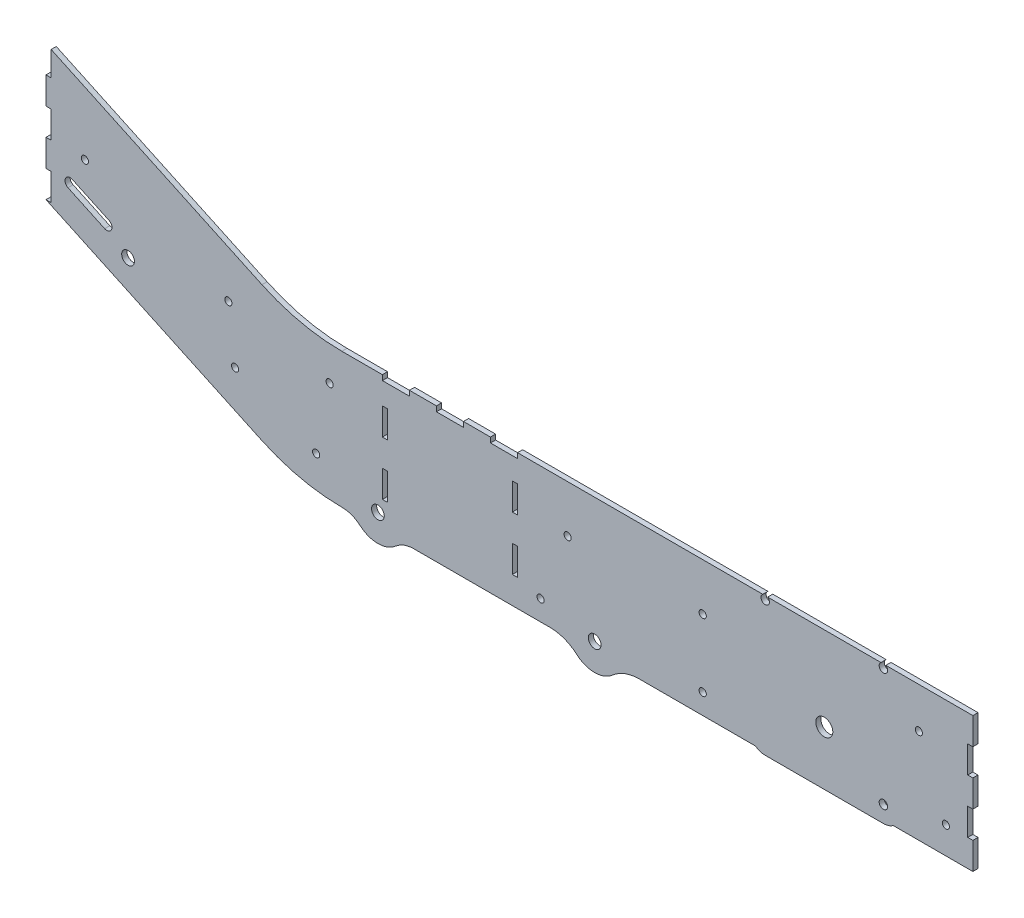
from build123d import *

# Parameters (mm, degrees)
SKETCH1_R           = 3.3782
SKETCH1_R_2         = 6
SKETCH1_R_3         = 8
BOSS_EXTRUDE1_DEPTH = 4.826
SKETCH2_W           = 4.826
SKETCH2_H           = 25.4
BOSS_EXTRUDE2_DEPTH = 4.826
SKETCH3_W           = 4.826
SKETCH3_H           = 25.4
CUT_EXTRUDE1_DEPTH  = 4.826
SKETCH4_W           = 4.826
SKETCH4_H           = 25.4
BOSS_EXTRUDE3_DEPTH = 4.826
SKETCH5_W           = 4.826
SKETCH5_H           = 25.4
CUT_EXTRUDE2_DEPTH  = 4.826
SKETCH6_W           = 4.826
SKETCH6_H           = 25.4
CUT_EXTRUDE3_DEPTH  = 9.652
SKETCH7_W           = 25.4
SKETCH7_H           = 4.826
CUT_EXTRUDE4_DEPTH  = 5.826
SKETCH9_W           = 4.826
SKETCH9_H           = 25.4
CUT_EXTRUDE5_DEPTH  = 5.826
BOSS_EXTRUDE4_DEPTH = 4.826
SKETCH11_R          = 4
CUT_EXTRUDE6_DEPTH  = 5.826


with BuildPart() as part:
    # Sketch1 → Boss-Extrude1 (new body)
    with BuildSketch(Plane.XY):
        with BuildLine():
            ThreePointArc((192.003501193, 390.374510077), (153.520537835, 394.589080012), (116.861974256, 407.032985542))
            Line((116.861974256, 407.032985542), (-86.189766395, 501.71756721))
            Line((-86.189766395, 501.71756721), (-86.189766395, 476.31756721))
            Line((-86.189766395, 476.31756721), (-81.363766395, 476.31756721))
            Line((-81.363766395, 476.31756721), (-81.363766395, 450.91756721))
            Line((-81.363766395, 450.91756721), (-86.189766395, 450.91756721))
            Line((-86.189766395, 450.91756721), (-86.189766395, 425.51756721))
            Line((-86.189766395, 425.51756721), (-81.363766395, 425.51756721))
            Line((-81.363766395, 425.51756721), (-81.363766395, 400.11756721))
            Line((-81.363766395, 400.11756721), (-86.189766395, 400.11756721))
            Line((-86.189766395, 400.11756721), (-86.189766395, 374.71756721))
            Line((-86.189766395, 374.71756721), (116.861974256, 280.032985542))
            ThreePointArc((116.861974256, 280.032985542), (153.520537835, 267.589080012), (192.003501193, 263.374510077))
            ThreePointArc((192.003501193, 263.374510077), (201.203503254, 261.71550325), (209.244538804, 256.947475478))
            ThreePointArc((209.244538804, 256.947475478), (225.871079853, 250.749510077), (242.497620902, 256.947475478))
            ThreePointArc((242.497620902, 256.947475478), (250.538656453, 261.71550325), (259.738658513, 263.374510077))
            Line((259.738658513, 263.374510077), (387.768126915, 263.374510077))
            ThreePointArc((387.768126915, 263.374510077), (401.20665362, 260.925821414), (412.917790929, 253.894510077))
            ThreePointArc((412.917790929, 253.894510077), (429.684233605, 247.574510077), (446.45067628, 253.894510077))
            ThreePointArc((446.45067628, 253.894510077), (458.161813589, 260.925821414), (471.600340294, 263.374510077))
            Line((471.600340294, 263.374510077), (624.413499087, 263.374510077))
            ThreePointArc((624.413499087, 263.374510077), (627.977205024, 263.123267502), (631.470410593, 262.374510077))
            ThreePointArc((631.470410593, 262.374510077), (645.584233605, 260.374510077), (659.698056616, 262.374510077))
            ThreePointArc((659.698056616, 262.374510077), (663.191262186, 263.123267502), (666.754968122, 263.374510077))
            Line((666.754968122, 263.374510077), (790.110233605, 263.374510077))
            Line((790.110233605, 263.374510077), (790.110233605, 288.774510077))
            Line((790.110233605, 288.774510077), (785.284233605, 288.774510077))
            Line((785.284233605, 288.774510077), (785.284233605, 314.174510077))
            Line((785.284233605, 314.174510077), (790.110233605, 314.174510077))
            Line((790.110233605, 314.174510077), (790.110233605, 339.574510077))
            Line((790.110233605, 339.574510077), (785.284233605, 339.574510077))
            Line((785.284233605, 339.574510077), (785.284233605, 364.974510077))
            Line((785.284233605, 364.974510077), (790.110233605, 364.974510077))
            Line((790.110233605, 364.974510077), (790.110233605, 390.374510077))
            Line((790.110233605, 390.374510077), (192.003501193, 390.374510077))
        make_face()
        with BuildLine():
            ThreePointArc((-26.914752452, 387.434325035), (-24.580466803, 381.020927923), (-30.993863915, 378.686642274))
            Line((-30.993863915, 378.686642274), (-65.524190601, 394.788398047))
            ThreePointArc((-65.524190601, 394.788398047), (-67.85847625, 401.201795158), (-61.445079138, 403.536080807))
            Line((-61.445079138, 403.536080807), (-26.914752452, 387.434325035))
        make_face(mode=Mode.SUBTRACT)
        with Locations((85.260233605, 377.674510077)):
            Circle(SKETCH1_R, mode=Mode.SUBTRACT)
        with Locations((-49.613766395, 425.51756721)):
            Circle(SKETCH1_R, mode=Mode.SUBTRACT)
        with Locations((225.871079853, 276.149510077)):
            Circle(SKETCH1_R_2, mode=Mode.SUBTRACT)
        with Locations((167.810233605, 295.124510077)):
            Circle(SKETCH1_R, mode=Mode.SUBTRACT)
        with Locations((91.610233605, 326.874510077)):
            Circle(SKETCH1_R, mode=Mode.SUBTRACT)
        with Locations((-9.032874317, 365.922075979)):
            Circle(SKETCH1_R_2, mode=Mode.SUBTRACT)
        with Locations((180.510233605, 358.624510077)):
            Circle(SKETCH1_R, mode=Mode.SUBTRACT)
        with Locations((429.684233605, 272.974510077)):
            Circle(SKETCH1_R_2, mode=Mode.SUBTRACT)
        with Locations((378.858833605, 282.424510077)):
            Circle(SKETCH1_R, mode=Mode.SUBTRACT)
        with Locations((531.258833605, 282.424510077)):
            Circle(SKETCH1_R, mode=Mode.SUBTRACT)
        with Locations((759.884233605, 288.774510077)):
            Circle(SKETCH1_R, mode=Mode.SUBTRACT)
        with Locations((404.258833605, 345.924510077)):
            Circle(SKETCH1_R, mode=Mode.SUBTRACT)
        with Locations((531.258833605, 345.924510077)):
            Circle(SKETCH1_R, mode=Mode.SUBTRACT)
        with Locations((645.584233605, 311.174510077)):
            Circle(SKETCH1_R_3, mode=Mode.SUBTRACT)
        with Locations((734.484233605, 352.274510077)):
            Circle(SKETCH1_R, mode=Mode.SUBTRACT)
    extrude(amount=BOSS_EXTRUDE1_DEPTH)

    # Sketch2 → Boss-Extrude2 (add)
    with BuildSketch(Plane(origin=(785.284233605, 0, 0), x_dir=(0, 0, -1), z_dir=(1, 0, 0))):
        with Locations((-2.413, 352.274510077)):
            Rectangle(SKETCH2_W, SKETCH2_H)
        with Locations((-2.413, 301.474510077)):
            Rectangle(SKETCH2_W, SKETCH2_H)
    extrude(amount=BOSS_EXTRUDE2_DEPTH)

    # Sketch3 → Cut-Extrude1 (cut)
    with BuildSketch(Plane(origin=(790.110233605, 0, 0), x_dir=(0, 0, -1), z_dir=(1, 0, 0))):
        with Locations((-2.413, 377.674510077)):
            Rectangle(SKETCH3_W, SKETCH3_H)
        with Locations((-2.413, 326.874510077)):
            Rectangle(SKETCH3_W, SKETCH3_H)
        with Locations((-2.413, 276.074510077)):
            Rectangle(SKETCH3_W, SKETCH3_H)
    extrude(amount=-CUT_EXTRUDE1_DEPTH, mode=Mode.SUBTRACT)

    # Sketch4 → Boss-Extrude3 (add)
    with BuildSketch(Plane.ZY.offset(81.363766395)):
        with Locations((2.413, 463.61756721)):
            Rectangle(SKETCH4_W, SKETCH4_H)
        with Locations((2.413, 412.81756721)):
            Rectangle(SKETCH4_W, SKETCH4_H)
    extrude(amount=BOSS_EXTRUDE3_DEPTH)

    # Sketch5 → Cut-Extrude2 (cut)
    with BuildSketch(Plane.ZY.offset(86.189766395)):
        with Locations((2.413, 387.41756721)):
            Rectangle(SKETCH5_W, SKETCH5_H)
        with Locations((2.413, 438.21756721)):
            Rectangle(SKETCH5_W, SKETCH5_H)
        with Locations((2.413, 489.01756721)):
            Rectangle(SKETCH5_W, SKETCH5_H)
    extrude(amount=-CUT_EXTRUDE2_DEPTH, mode=Mode.SUBTRACT)

    # Sketch6 → Cut-Extrude3 (cut)
    with BuildSketch(Plane(origin=(790.110233605, 0, 0), x_dir=(0, 0, -1), z_dir=(1, 0, 0))):
        with Locations((-2.413, 352.274510077)):
            Rectangle(SKETCH6_W, SKETCH6_H)
        with Locations((-2.413, 301.474510077)):
            Rectangle(SKETCH6_W, SKETCH6_H)
    extrude(amount=-CUT_EXTRUDE3_DEPTH, mode=Mode.SUBTRACT)

    # Sketch7 → Cut-Extrude4 (cut, through all)
    with BuildSketch(Plane.XY.offset(4.826)):
        with Locations((293.603501193, 387.961510077)):
            Rectangle(SKETCH7_W, SKETCH7_H)
        with Locations((344.403501193, 387.961510077)):
            Rectangle(SKETCH7_W, SKETCH7_H)
        with Locations((242.803501193, 387.961510077)):
            Rectangle(SKETCH7_W, SKETCH7_H)
    extrude(amount=-CUT_EXTRUDE4_DEPTH, mode=Mode.SUBTRACT)

    # Sketch9 → Cut-Extrude5 (cut, through all)
    with BuildSketch(Plane(origin=(0, 0, 0), x_dir=(-1, 0, 0), z_dir=(0, 0, -1))):
        with Locations((-354.690501193, 352.274510077)):
            Rectangle(SKETCH9_W, SKETCH9_H)
        with Locations((-354.690501193, 301.474510077)):
            Rectangle(SKETCH9_W, SKETCH9_H)
        with Locations((-232.516501193, 301.474510077)):
            Rectangle(SKETCH9_W, SKETCH9_H)
        with Locations((-232.516501193, 352.274510077)):
            Rectangle(SKETCH9_W, SKETCH9_H)
    extrude(amount=-CUT_EXTRUDE5_DEPTH, mode=Mode.SUBTRACT)

    # Sketch10 → Boss-Extrude4 (add)
    with BuildSketch(Plane.XY.offset(4.826)):
        with BuildLine():
            ThreePointArc((580.854886872, 263.374510077), (585.212430925, 261.14348344), (590.047133605, 260.374510077))
            Line((590.047133605, 260.374510077), (645.584233605, 260.374510077))
            ThreePointArc((645.584233605, 260.374510077), (638.456821732, 260.876995228), (631.470410593, 262.374510077))
            ThreePointArc((631.470410593, 262.374510077), (627.977205024, 263.123267502), (624.413499087, 263.374510077))
            Line((624.413499087, 263.374510077), (580.854886872, 263.374510077))
        make_face()
        with BuildLine():
            ThreePointArc((659.698056616, 262.374510077), (652.711645477, 260.876995228), (645.584233605, 260.374510077))
            Line((645.584233605, 260.374510077), (701.172133605, 260.374510077))
            ThreePointArc((701.172133605, 260.374510077), (706.006836284, 261.14348344), (710.364380338, 263.374510077))
            Line((710.364380338, 263.374510077), (666.754968122, 263.374510077))
            ThreePointArc((666.754968122, 263.374510077), (663.191262186, 263.123267502), (659.698056616, 262.374510077))
        make_face()
    extrude(amount=-BOSS_EXTRUDE4_DEPTH)

    # Sketch11 → Cut-Extrude6 (cut, through all)
    with BuildSketch(Plane.XY.offset(4.826)):
        with Locations((590.047133605, 387.082410077)):
            Circle(SKETCH11_R)
        with Locations((701.172133605, 387.082410077)):
            Circle(SKETCH11_R)
        with Locations((701.172133605, 275.957410077)):
            Circle(SKETCH11_R)
        with Locations((590.047133605, 240.977875999)):
            Circle(SKETCH11_R)
    extrude(amount=-CUT_EXTRUDE6_DEPTH, mode=Mode.SUBTRACT)


solid = part.part
